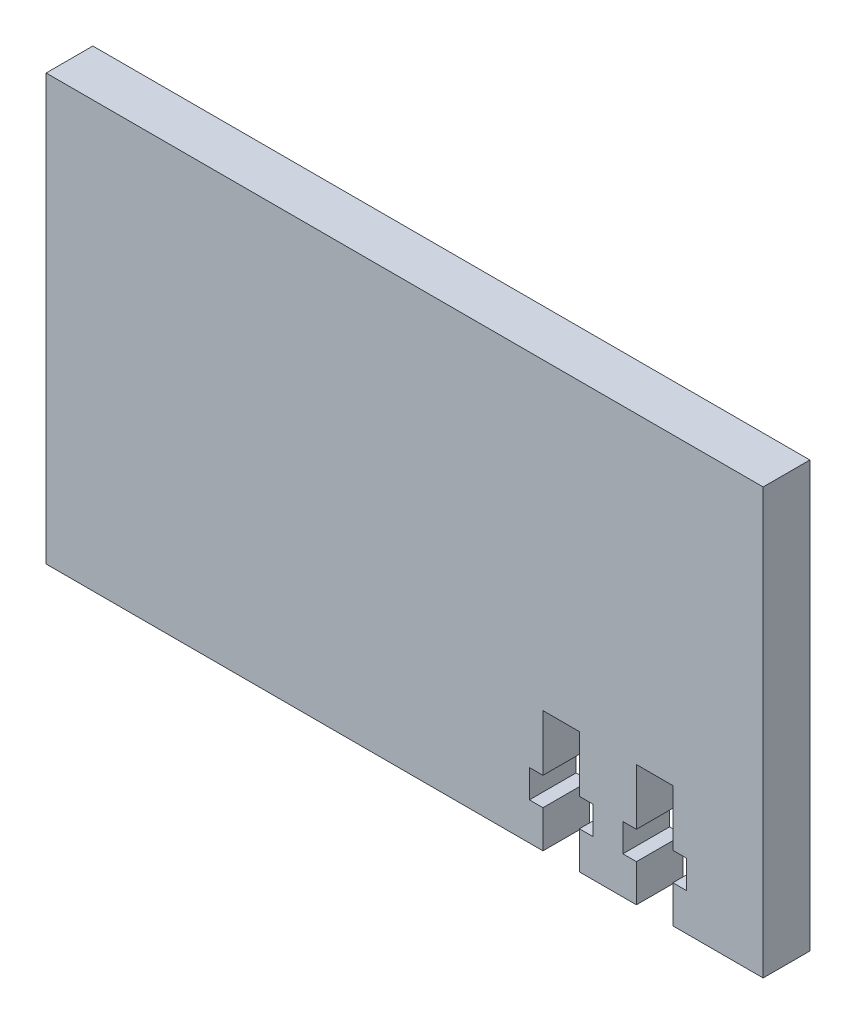
from build123d import *

# Parameters (mm, degrees)
SKETCH2_W           = 76.718161642
SKETCH2_H           = 45.5
BOSS_EXTRUDE1_DEPTH = 5
CUT_EXTRUDE1_DEPTH  = 10


with BuildPart() as part:
    # Sketch2 → Boss-Extrude1 (new body)
    with BuildSketch(Plane(origin=(0, 0, 0), x_dir=(-1, 0, 0), z_dir=(0, 0, -1))):
        with Locations((184.636580821, -32.25)):
            Rectangle(SKETCH2_W, SKETCH2_H)
    extrude(amount=BOSS_EXTRUDE1_DEPTH)

    # Sketch3 → Cut-Extrude1 (cut)
    with BuildSketch(Plane(origin=(0, 0, -5), x_dir=(-1, 0, 0), z_dir=(0, 0, -1))):
        Polygon((155.9375, -55), (155.9375, -51), (154.4875, -51), (154.4875, -48), (155.9375, -48), (155.9375, -42), (159.8375, -42), (159.8375, -48), (161.2875, -48), (161.2875, -51), (159.8375, -51), (159.8375, -55), align=None)
        Polygon((165.9375, -55), (165.9375, -51), (164.4875, -51), (164.4875, -48), (165.9375, -48), (165.9375, -42), (169.8375, -42), (169.8375, -48), (171.2875, -48), (171.2875, -51), (169.8375, -51), (169.8375, -55), align=None)
    extrude(amount=-CUT_EXTRUDE1_DEPTH, mode=Mode.SUBTRACT)


solid = part.part
